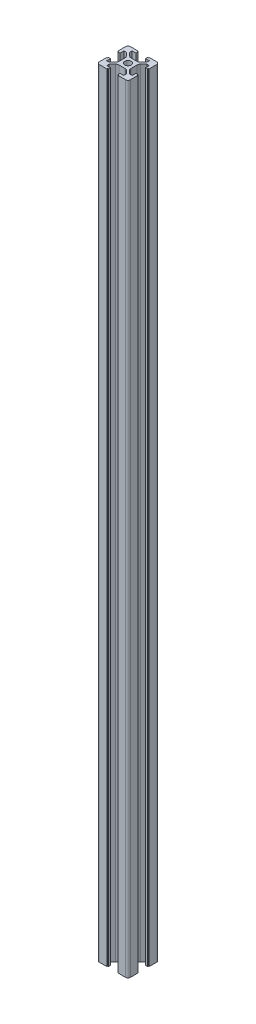
from build123d import *

# Parameters (mm, degrees)
SKETCH1_W           = 20
SKETCH1_H           = 20
SKETCH1_R           = 2.1
BOSS_EXTRUDE1_DEPTH = 500
CUT_EXTRUDE1_DEPTH  = 501.199960016
CIRPATTERN1_COUNT   = 4
FILLET1_R           = 1.5


with BuildPart() as part:
    # Sketch1 → Boss-Extrude1 (new body)
    with BuildSketch(Plane(origin=(0, 0, 0), x_dir=(1, 0, 0), z_dir=(0, 1, 0))):
        Rectangle(SKETCH1_W, SKETCH1_H)
        Circle(SKETCH1_R, mode=Mode.SUBTRACT)
    extrude(amount=BOSS_EXTRUDE1_DEPTH)

    # Sketch2 → Cut-Extrude1 (cut, symmetric)
    with BuildSketch(Plane(origin=(0, 500, 0), x_dir=(1, 0, 0), z_dir=(0, 1, 0))):
        with BuildLine():
            Line((-2.010912703, 3.9), (2.010912703, 3.9))
            ThreePointArc((2.010912703, 3.9), (2.776279568, 4.052240935), (3.425126266, 4.485786438))
            Line((3.425126266, 4.485786438), (5.5, 6.560660172))
            Line((5.5, 6.560660172), (5.5, 8.2))
            Line((5.5, 8.2), (3.1, 8.2))
            Line((3.1, 8.2), (3.1, 9.5))
            Line((3.1, 9.5), (3.4, 9.5))
            ThreePointArc((3.4, 9.5), (3.541421356, 9.558578644), (3.6, 9.7))
            Line((3.6, 9.7), (3.6, 10))
            Line((3.6, 10), (-3.6, 10))
            Line((-3.6, 10), (-3.6, 9.7))
            ThreePointArc((-3.6, 9.7), (-3.541421356, 9.558578644), (-3.4, 9.5))
            Line((-3.4, 9.5), (-3.1, 9.5))
            Line((-3.1, 9.5), (-3.1, 8.2))
            Line((-3.1, 8.2), (-5.5, 8.2))
            Line((-5.5, 8.2), (-5.5, 6.560660172))
            Line((-5.5, 6.560660172), (-3.425126266, 4.485786438))
            ThreePointArc((-3.425126266, 4.485786438), (-2.776279568, 4.052240935), (-2.010912703, 3.9))
        make_face()
    cut_extrude1 = extrude(amount=CUT_EXTRUDE1_DEPTH, both=True, mode=Mode.SUBTRACT)

    # CirPattern1: Cut-Extrude1 ×4 about axis
    cirpattern1_axis = Axis((0, 500, 0), (0, -1, 0))
    for i in range(1, CIRPATTERN1_COUNT):
        add(cut_extrude1.rotate(cirpattern1_axis, i * 360 / CIRPATTERN1_COUNT), mode=Mode.SUBTRACT)

    # Fillet1
    fillet1_edges = [part.edges().sort_by_distance(p)[0] for p in [
        (10, 250, 10),
        (10, 250, -10),
        (-10, 250, 10),
        (-10, 250, -10),
    ]]
    fillet(fillet1_edges, radius=FILLET1_R)


solid = part.part
